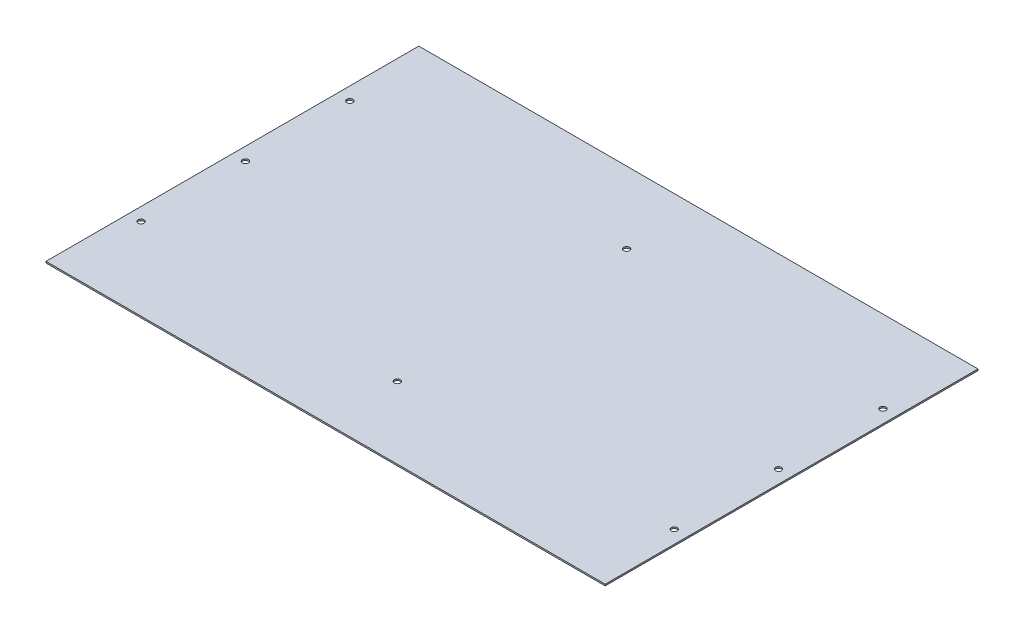
from build123d import *

# Parameters (mm, degrees)
SKETCH1_W           = 750
SKETCH1_H           = 500
BOSS_EXTRUDE1_DEPTH = 2
SKETCH2_R           = 4
CUT_EXTRUDE1_DEPTH  = 2
SKETCH3_R           = 4
CUT_EXTRUDE2_DEPTH  = 2


with BuildPart() as part:
    # Sketch1 → Boss-Extrude1 (new body)
    with BuildSketch(Plane(origin=(0, 0, 0), x_dir=(1, 0, 0), z_dir=(0, 1, 0))):
        Rectangle(SKETCH1_W, SKETCH1_H)
    extrude(amount=BOSS_EXTRUDE1_DEPTH)

    # Sketch2 → Cut-Extrude1 (cut)
    with BuildSketch(Plane(origin=(0, 2, 0), x_dir=(1, 0, 0), z_dir=(0, 1, 0))):
        with Locations((-357.5, 0)):
            Circle(SKETCH2_R)
        with Locations((-357.5, 140)):
            Circle(SKETCH2_R)
        with Locations((-357.5, -140)):
            Circle(SKETCH2_R)
    cut_extrude1 = extrude(amount=-CUT_EXTRUDE1_DEPTH, mode=Mode.SUBTRACT)

    # Mirror1: Cut-Extrude1 across plane
    add(cut_extrude1.mirror(Plane(origin=(0, 0, 0), x_dir=(0, 0, 1), z_dir=(1, 0, 0))), mode=Mode.SUBTRACT)

    # Sketch3 → Cut-Extrude2 (cut)
    with BuildSketch(Plane(origin=(0, 2, 0), x_dir=(1, 0, 0), z_dir=(0, 1, 0))):
        with Locations((0, 153.75)):
            Circle(SKETCH3_R)
        with Locations((0, -153.75)):
            Circle(SKETCH3_R)
    extrude(amount=-CUT_EXTRUDE2_DEPTH, mode=Mode.SUBTRACT)


solid = part.part
